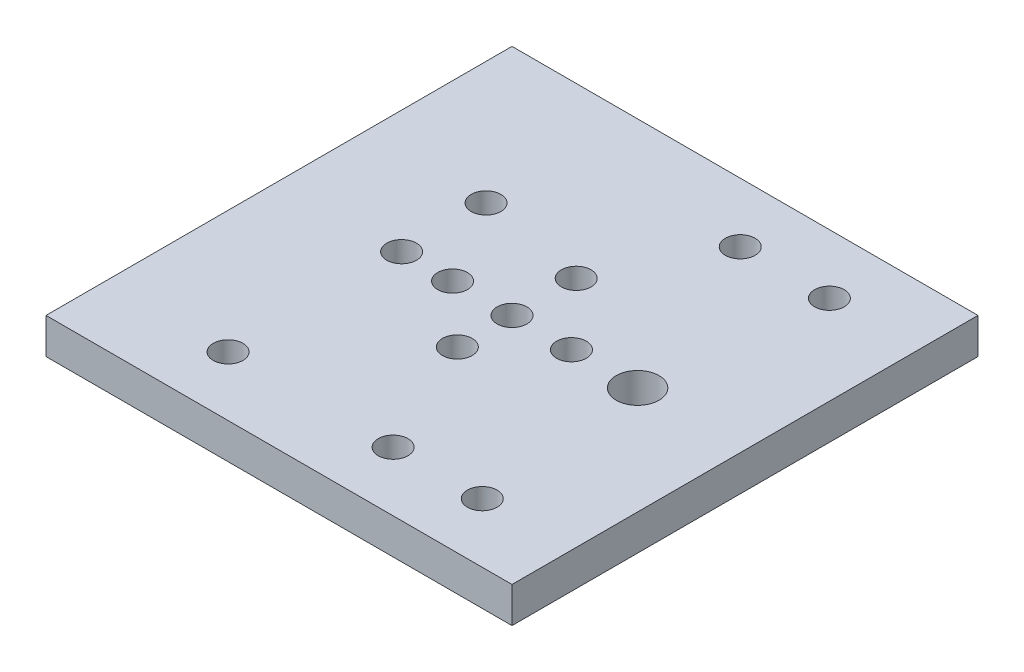
from build123d import *

# Parameters (mm, degrees)
SKETCH1_W           = 78.398472783
SKETCH1_H           = 78.398472783
SKETCH1_R           = 2.5
SKETCH1_R_2         = 3.6
BOSS_EXTRUDE1_DEPTH = 6


with BuildPart() as part:
    # Sketch1 → Boss-Extrude1 (new body)
    with BuildSketch(Plane(origin=(0, 0, 0), x_dir=(1, 0, 0), z_dir=(0, 1, 0))):
        with Locations((40.375415283, -9.795284327)):
            Rectangle(SKETCH1_W, SKETCH1_H)
        with Locations((21.806637056, 4.403952064)):
            Circle(SKETCH1_R, mode=Mode.SUBTRACT)
        with Locations((21.806637056, -38.994520719)):
            Circle(SKETCH1_R, mode=Mode.SUBTRACT)
        with Locations((64.574651674, 19.403952064)):
            Circle(SKETCH1_R, mode=Mode.SUBTRACT)
        with Locations((49.574651674, 19.403952064)):
            Circle(SKETCH1_R, mode=Mode.SUBTRACT)
        with Locations((61.506637056, -9.795284327)):
            Circle(SKETCH1_R_2, mode=Mode.SUBTRACT)
        with Locations((40.375415282, -9.795284327)):
            Circle(SKETCH1_R, mode=Mode.SUBTRACT)
        with Locations((30.375415282, -9.795284327)):
            Circle(SKETCH1_R, mode=Mode.SUBTRACT)
        with Locations((21.806637056, -9.795284327)):
            Circle(SKETCH1_R, mode=Mode.SUBTRACT)
        with Locations((50.375415282, -9.795284327)):
            Circle(SKETCH1_R, mode=Mode.SUBTRACT)
        with Locations((64.574651674, -38.994520719)):
            Circle(SKETCH1_R, mode=Mode.SUBTRACT)
        with Locations((49.574651674, -38.994520719)):
            Circle(SKETCH1_R, mode=Mode.SUBTRACT)
        with Locations((40.375415282, -18.994520719)):
            Circle(SKETCH1_R, mode=Mode.SUBTRACT)
        with Locations((40.375415282, 1.005479281)):
            Circle(SKETCH1_R, mode=Mode.SUBTRACT)
    extrude(amount=BOSS_EXTRUDE1_DEPTH)


solid = part.part
